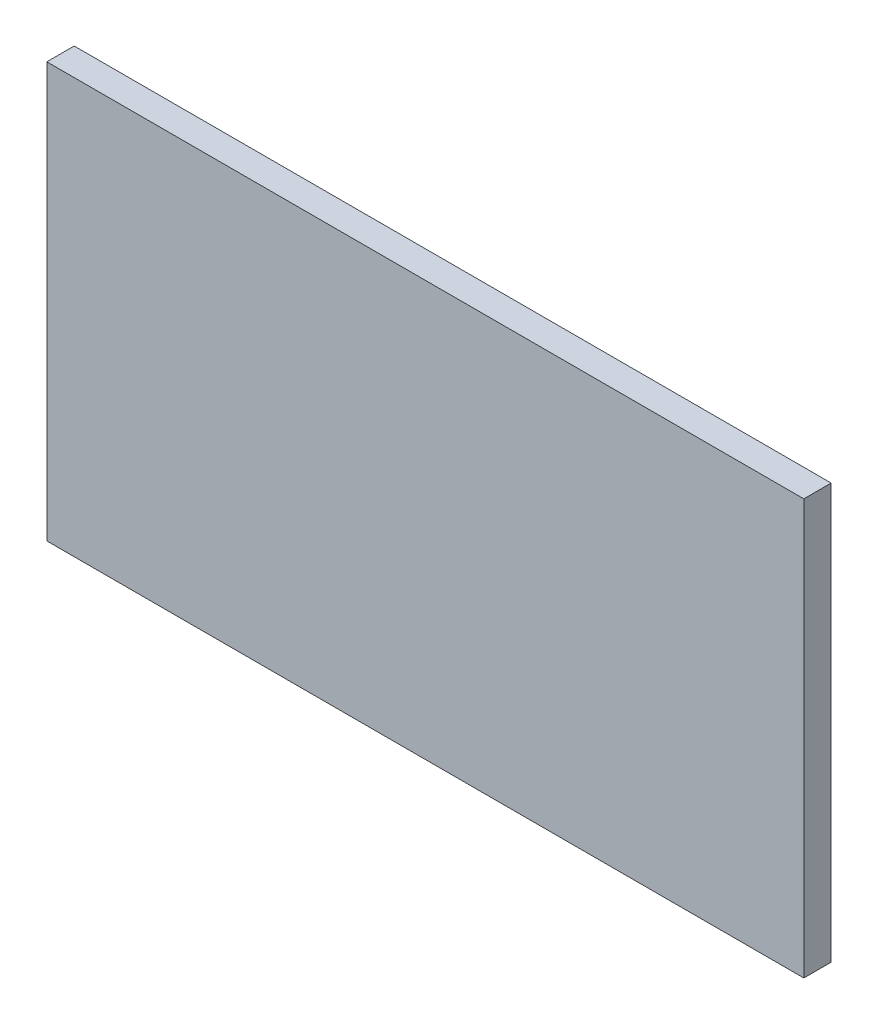
from build123d import *

# Parameters (mm, degrees)
SKETCH1_W           = 41.5
SKETCH1_H           = 22.75
BOSS_EXTRUDE1_DEPTH = 1.5
SKETCH1_3_W         = 4
SKETCH1_3_H         = 3
SKETCH1_3_W_2       = 4.75
SKETCH1_3_H_2       = 12
BOSS_EXTRUDE2_DEPTH = 2


with BuildPart() as part:
    # Sketch1 → Boss-Extrude1 (new body)
    with BuildSketch(Plane.XY):
        with Locations((20.75, 11.375)):
            Rectangle(SKETCH1_W, SKETCH1_H)
    extrude(amount=BOSS_EXTRUDE1_DEPTH)

    # Sketch1_3 → Boss-Extrude2 (add)
    with BuildSketch(Plane.XY):
        with Locations((7.5, 13.75)):
            Rectangle(SKETCH1_3_W, SKETCH1_3_H)
        with Locations((22.125, 9)):
            Rectangle(SKETCH1_3_W_2, SKETCH1_3_H_2)
    extrude(amount=-BOSS_EXTRUDE2_DEPTH)


solid = part.part
